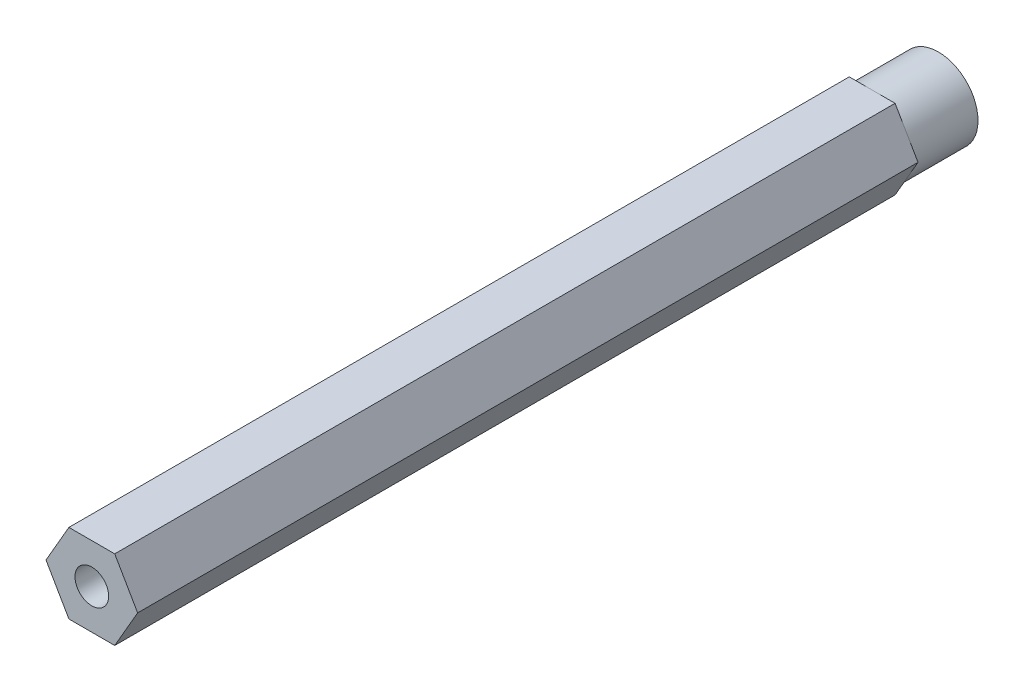
from build123d import *

# Parameters (mm, degrees)
BOSS_EXTRUDE1_DEPTH    = 101.6
F_10_32_TAPPED_HOLE1_D = 4.0386
SKETCH5_OUTSIDE_W      = 33.526
SKETCH5_OUTSIDE_H      = 32.054
SKETCH5_OUTSIDE_R      = 4.7625
CUT_EXTRUDE1_DEPTH     = 7.9375


with BuildPart() as part:
    # Sketch1 → Boss-Extrude1 (new body)
    with BuildSketch(Plane.XY):
        Polygon((2.749630657, -4.7625), (5.499261314, 0), (2.749630657, 4.7625), (-2.749630657, 4.7625), (-5.499261314, 0), (-2.749630657, -4.7625), align=None)
    extrude(amount=BOSS_EXTRUDE1_DEPTH)

    # #10-32 Tapped Hole1 (through all)
    with Locations(Plane.XY.offset(101.6)):
        with Locations((0, 0)):
            Hole(F_10_32_TAPPED_HOLE1_D / 2)

    # Sketch5 outside → Cut-Extrude1 (cut)
    with BuildSketch(Plane(origin=(0, 0, 0), x_dir=(-1, 0, 0), z_dir=(0, 0, -1))):
        Rectangle(SKETCH5_OUTSIDE_W, SKETCH5_OUTSIDE_H)
        with Locations(Location((0, 0, 0), (0, 0, 330))):  # turned: the seam where the file's is
            Circle(SKETCH5_OUTSIDE_R, mode=Mode.SUBTRACT)
    extrude(amount=-CUT_EXTRUDE1_DEPTH, mode=Mode.SUBTRACT)


solid = part.part
